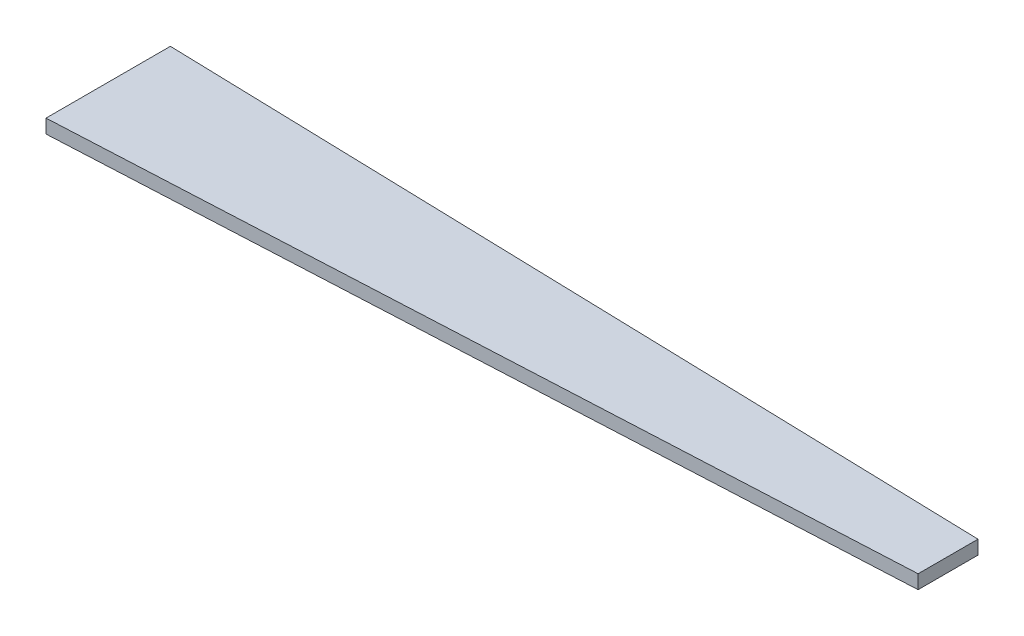
from build123d import *

# Parameters (mm, degrees)
AUFSATZ_LINEAR_AUSTRAGEN1_DEPTH = 30


with BuildPart() as part:
    # Skizze2 → Aufsatz-Linear austragen1 (new body)
    with BuildSketch(Plane(origin=(0, 0, 0), x_dir=(1, 0, 0), z_dir=(0, 1, 0))):
        Polygon((0, 0), (0, -270), (1803.217183174, -180), (1803.217183174, -50), align=None)
    extrude(amount=AUFSATZ_LINEAR_AUSTRAGEN1_DEPTH)


solid = part.part
